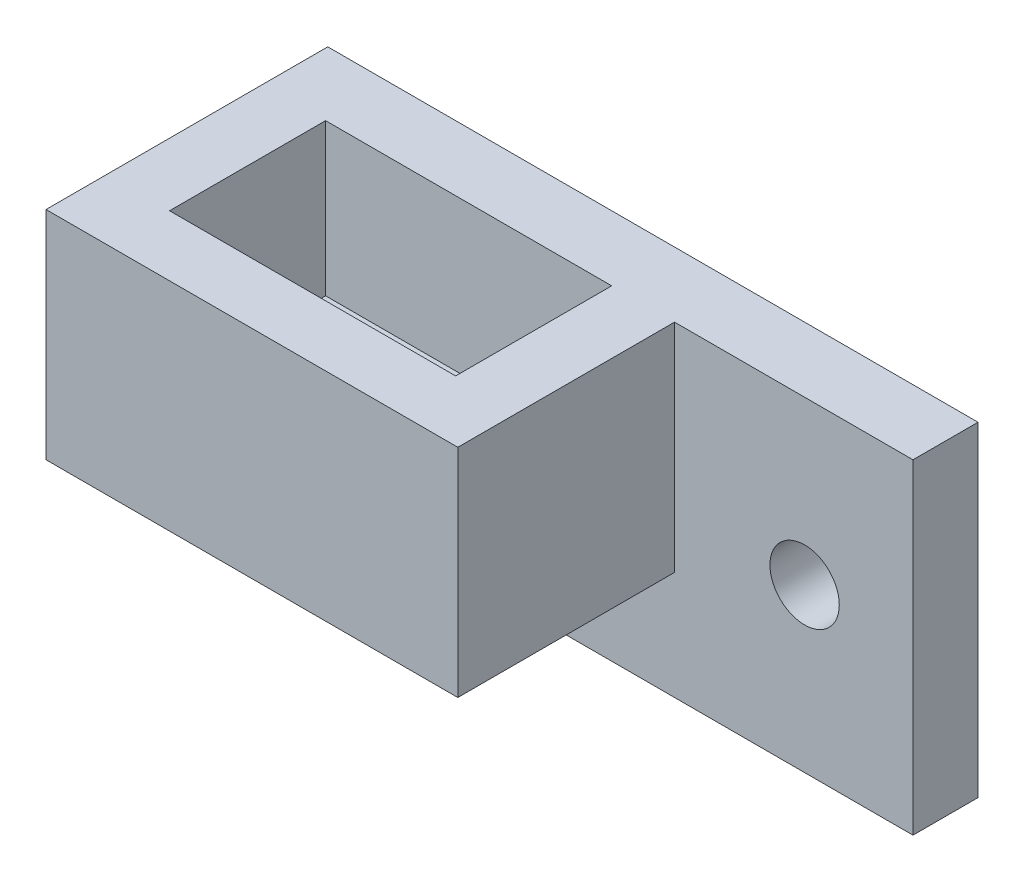
from build123d import *

# Parameters (mm, degrees)
CROQUIS1_R              = 1.6
SALIENTE_EXTRUIR1_DEPTH = 3
CROQUIS2_W              = 19
CROQUIS2_H              = 10
SALIENTE_EXTRUIR2_DEPTH = 10
CROQUIS3_W              = 13.2
CROQUIS3_H              = 7.2
CORTAR_EXTRUIR1_DEPTH   = 7
CROQUIS4_R              = 3.2
CORTAR_EXTRUIR2_DEPTH   = 3
CROQUIS5_W              = 10
CROQUIS5_H              = 5
SALIENTE_EXTRUIR3_DEPTH = 3


with BuildPart() as part:
    # Croquis1 → Saliente-Extruir1 (new body)
    with BuildSketch(Plane.XY):
        Polygon((-13.299831285, 0), (-28.299831285, 0), (-28.299831285, 5), (-43.299831285, 5), (-43.299831285, 15), (-13.299831285, 15), align=None)
        with Locations((-18.299831285, 7.5)):
            Circle(CROQUIS1_R, mode=Mode.SUBTRACT)
    extrude(amount=SALIENTE_EXTRUIR1_DEPTH)

    # Croquis2 → Saliente-Extruir2 (add)
    with BuildSketch(Plane.XY.offset(3)):
        with Locations((-33.799831285, 10)):
            Rectangle(CROQUIS2_W, CROQUIS2_H)
    extrude(amount=SALIENTE_EXTRUIR2_DEPTH)

    # Croquis3 → Cortar-Extruir1 (cut)
    with BuildSketch(Plane(origin=(0, 15, 0), x_dir=(1, 0, 0), z_dir=(0, 1, 0))):
        with Locations((-33.799831285, -6.6)):
            Rectangle(CROQUIS3_W, CROQUIS3_H)
    extrude(amount=-CORTAR_EXTRUIR1_DEPTH, mode=Mode.SUBTRACT)

    # Croquis4 → Cortar-Extruir2 (cut)
    with BuildSketch(Plane(origin=(0, 8, 0), x_dir=(1, 0, 0), z_dir=(0, 1, 0))):
        with Locations((-33.799831285, -6.5)):
            Circle(CROQUIS4_R)
    extrude(amount=-CORTAR_EXTRUIR2_DEPTH, mode=Mode.SUBTRACT)

    # Croquis5 → Saliente-Extruir3 (add)
    with BuildSketch(Plane.ZY.offset(28.299831285)):
        with Locations((-2, 2.5)):
            Rectangle(CROQUIS5_W, CROQUIS5_H)
    extrude(amount=SALIENTE_EXTRUIR3_DEPTH)


solid = part.part
